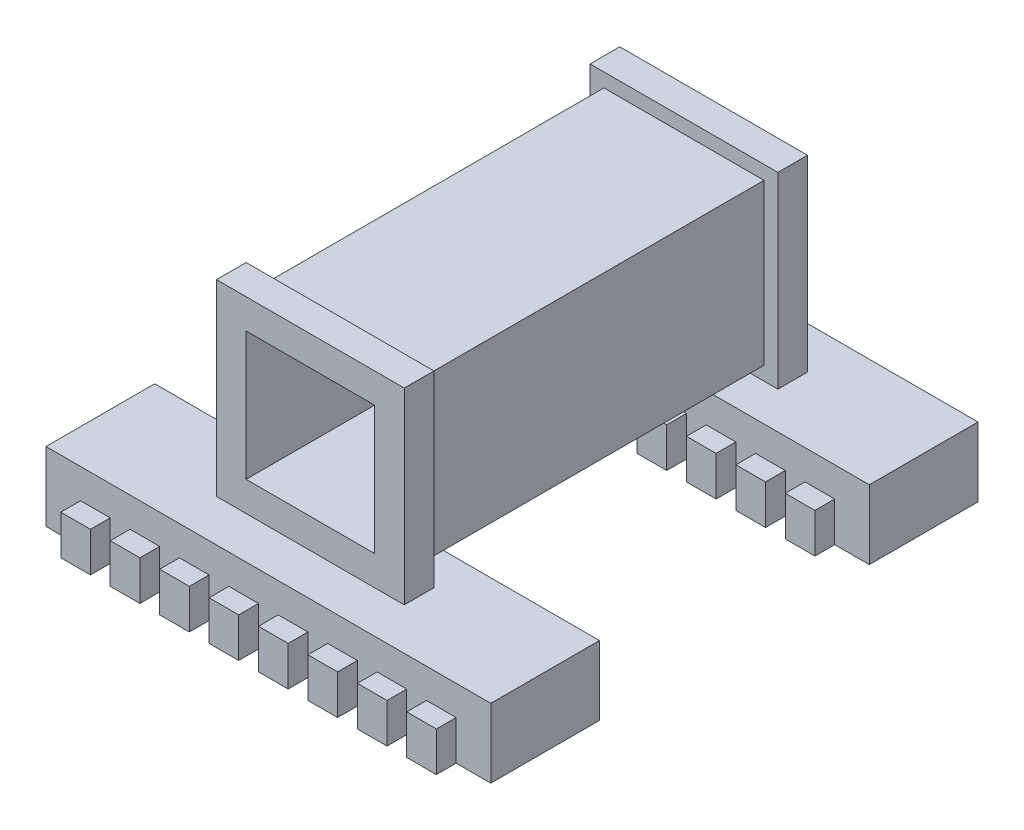
from build123d import *

# Parameters (mm, degrees)
SKETCH_1_W           = 19
SKETCH_1_H           = 19
SKETCH_1_W_2         = 13
SKETCH_1_H_2         = 13
EXTRUDE_2_DEPTH      = 20.4
SKETCH_1_3_W         = 19
SKETCH_1_3_H         = 19
SKETCH_1_3_W_2       = 16.2
SKETCH_1_3_H_2       = 16.2
CUT_EXTRUDE_1_DEPTH  = 17.4
EXTRUDE_4_DEPTH      = 26.65
CUT_EXTRUDE_4_DEPTH  = 11.65
CUT_EXTRUDE_9_DEPTH  = 2
CUT_EXTRUDE_10_DEPTH = 2
CUT_EXTRUDE_11_DEPTH = 2
CUT_EXTRUDE_12_DEPTH = 2
SKETCH_12_W          = 39
SKETCH_12_H          = 3.5
CUT_EXTRUDE_13_DEPTH = 4


with BuildPart() as part:
    # 草图1 → 凸台-拉伸2 (new, symmetric)
    with BuildSketch(Plane.XY):
        Rectangle(SKETCH_1_W, SKETCH_1_H)
        Rectangle(SKETCH_1_W_2, SKETCH_1_H_2, mode=Mode.SUBTRACT)
    extrude(amount=EXTRUDE_2_DEPTH, both=True)

    # 草图1<3> → 切除-拉伸1 (cut, symmetric)
    with BuildSketch(Plane.XY):
        Rectangle(SKETCH_1_3_W, SKETCH_1_3_H)
        Rectangle(SKETCH_1_3_W_2, SKETCH_1_3_H_2, mode=Mode.SUBTRACT)
    extrude(amount=CUT_EXTRUDE_1_DEPTH, both=True, mode=Mode.SUBTRACT)

    # 草图2 → 凸台-拉伸4 (add, symmetric)
    with BuildSketch(Plane.XY):
        Polygon((22.5, -9.5), (0, -9.5), (-22.5, -9.5), (-22.5, -16.5), (22.5, -16.5), align=None)
    extrude(amount=EXTRUDE_4_DEPTH, both=True)

    # 草图2<6> → 切除-拉伸4 (cut, symmetric)
    with BuildSketch(Plane.XY):
        Polygon((22.5, -9.5), (0, -9.5), (-22.5, -9.5), (-22.5, -16.5), (22.5, -16.5), align=None)
    extrude(amount=CUT_EXTRUDE_4_DEPTH, both=True, mode=Mode.SUBTRACT)

    # 草图4 → 切除-拉伸9 (cut)
    with BuildSketch(Plane(origin=(0, 0, -26.65), x_dir=(-1, 0, 0), z_dir=(0, 0, -1))):
        Polygon((-6, -12.5), (-6, -16.5), (-4, -16.5), (-4, -12.5), (-2.5, -12.5), (-1, -12.5), (-1, -16.5), (1, -16.5), (1, -12.5), (2.5, -12.5), (4, -12.5), (4, -16.5), (6, -16.5), (6, -12.5), (7.5, -12.5), (9, -12.5), (9, -16.5), (11, -16.5), (11, -12.5), (12.5, -12.5), (14, -12.5), (14, -16.5), (16, -16.5), (16, -12.5), (17.5, -12.5), (19, -12.5), (19, -16.5), (22.5, -16.5), (22.5, -9.5), (-22.5, -9.5), (-22.5, -16.5), (-19, -16.5), (-19, -12.5), (-17.5, -12.5), (-16, -12.5), (-16, -16.5), (-14, -16.5), (-14, -12.5), (-12.5, -12.5), (-11, -12.5), (-11, -16.5), (-9, -16.5), (-9, -12.5), (-7.5, -12.5), align=None)
    extrude(amount=-CUT_EXTRUDE_9_DEPTH, mode=Mode.SUBTRACT)

    # 草图9 → 切除-拉伸10 (cut)
    with BuildSketch(Plane.XY.offset(-11.65)):
        Polygon((-4, -12.5), (-1, -12.5), (-1, -16.5), (1, -16.5), (1, -12.5), (4, -12.5), (4, -16.5), (6, -16.5), (6, -12.5), (9, -12.5), (9, -16.5), (11, -16.5), (11, -12.5), (14, -12.5), (14, -16.5), (16, -16.5), (16, -12.5), (19, -12.5), (19, -16.5), (22.5, -16.5), (22.5, -9.5), (-22.5, -9.5), (-22.5, -16.5), (-19, -16.5), (-19, -12.5), (-16, -12.5), (-16, -16.5), (-14, -16.5), (-14, -12.5), (-11, -12.5), (-11, -16.5), (-9, -16.5), (-9, -12.5), (-6, -12.5), (-6, -16.5), (-4, -16.5), align=None)
    extrude(amount=-CUT_EXTRUDE_10_DEPTH, mode=Mode.SUBTRACT)

    # 草图10 → 切除-拉伸11 (cut)
    with BuildSketch(Plane(origin=(0, 0, 11.65), x_dir=(-1, 0, 0), z_dir=(0, 0, -1))):
        Polygon((1, -16.5), (1, -12.5), (4, -12.5), (4, -16.5), (6, -16.5), (6, -12.5), (9, -12.5), (9, -16.5), (11, -16.5), (11, -12.5), (14, -12.5), (14, -16.5), (16, -16.5), (16, -12.5), (19, -12.5), (19, -16.5), (22.5, -16.5), (22.5, -9.5), (-22.5, -9.5), (-22.5, -16.5), (-19, -16.5), (-19, -12.5), (-16, -12.5), (-16, -16.5), (-14, -16.5), (-14, -12.5), (-11, -12.5), (-11, -16.5), (-9, -16.5), (-9, -12.5), (-6, -12.5), (-6, -16.5), (-4, -16.5), (-4, -12.5), (-1, -12.5), (-1, -16.5), align=None)
    extrude(amount=-CUT_EXTRUDE_11_DEPTH, mode=Mode.SUBTRACT)

    # 草图11 → 切除-拉伸12 (cut)
    with BuildSketch(Plane.XY.offset(26.65)):
        Polygon((-1, -12.5), (-1, -16.5), (1, -16.5), (1, -12.5), (4, -12.5), (4, -16.5), (6, -16.5), (6, -12.5), (9, -12.5), (9, -16.5), (11, -16.5), (11, -12.5), (14, -12.5), (14, -16.5), (16, -16.5), (16, -12.5), (19, -12.5), (19, -16.5), (22.5, -16.5), (22.5, -9.5), (-22.5, -9.5), (-22.5, -16.5), (-19, -16.5), (-19, -12.5), (-16, -12.5), (-16, -16.5), (-14, -16.5), (-14, -12.5), (-11, -12.5), (-11, -16.5), (-9, -16.5), (-9, -12.5), (-6, -12.5), (-6, -16.5), (-4, -16.5), (-4, -12.5), align=None)
    extrude(amount=-CUT_EXTRUDE_12_DEPTH, mode=Mode.SUBTRACT)

    # 草图12 → 切除-拉伸13 (cut)
    with BuildSketch(Plane.XZ.offset(16.5)):
        with Locations((0, 21.65)):
            Rectangle(SKETCH_12_W, SKETCH_12_H)
        with Locations((0, -21.65)):
            Rectangle(SKETCH_12_W, SKETCH_12_H)
        with Locations((0, -16.65)):
            Rectangle(SKETCH_12_W, SKETCH_12_H)
        with Locations((0, 16.65)):
            Rectangle(SKETCH_12_W, SKETCH_12_H)
    extrude(amount=-CUT_EXTRUDE_13_DEPTH, mode=Mode.SUBTRACT)


solid = part.part
